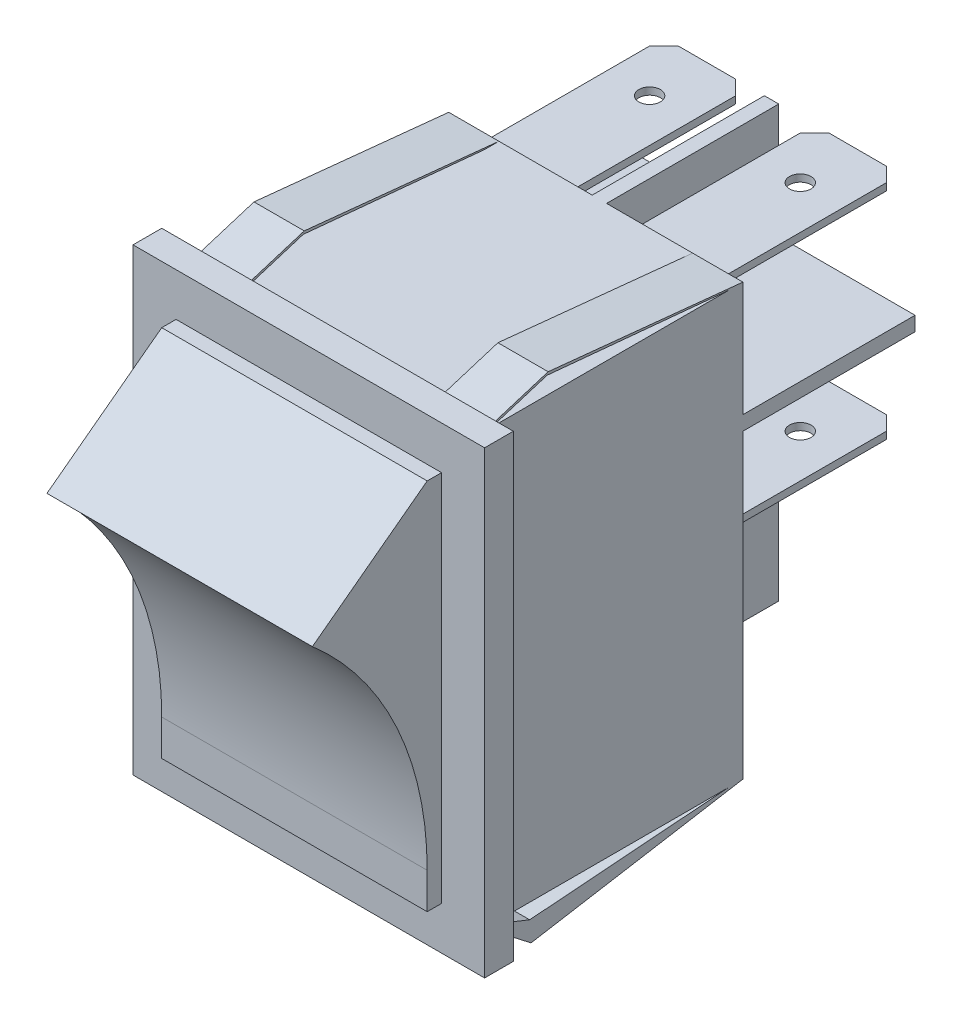
from build123d import *

# Parameters (mm, degrees)
SKETCH1_W                = 24.5
SKETCH1_H                = 32
EXTRUDE2_DEPTH           = 2
SKETCH2_W                = 20.5
SKETCH2_H                = 30
EXTRUDE3_DEPTH           = 18
SKETCH4_W                = 18.5
SKETCH4_H                = 26
EXTRUDE7_DEPTH           = 1
EXTRUDE8_DEPTH           = 18.5
EXTRUDE9_DEPTH           = 3.5
EXTRUDE10_DEPTH          = 3.5
EXTRUDE11_DEPTH          = 3.5
EXTRUDE12_DEPTH          = 3.5
SKETCH10_W               = 1
SKETCH10_H               = 30
EXTRUDE13_DEPTH          = 12
SKETCH11_W               = 9.5
SKETCH11_H               = 1
SKETCH11_W_2             = 10
EXTRUDE14_DEPTH          = 12
SKETCH12_W               = 6
SKETCH12_H               = 0.5
EXTRUDE15_DEPTH          = 13
CHAMFER1_SIZE            = 1
SKETCH14_R               = 0.75
CUT_EXTRUDE2_DEPTH       = 1
TAGLIO_ESTRUSIONE1_REACH = 18.5
SKETCH13_R               = 0.75


with BuildPart() as part:
    # Sketch1 → Extrude2 (new body)
    with BuildSketch(Plane.XY):
        with Locations((-1.666405536, 7.433431257)):
            Rectangle(SKETCH1_W, SKETCH1_H)
    extrude(amount=EXTRUDE2_DEPTH)

    # Sketch2 → Extrude3 (add)
    with BuildSketch(Plane(origin=(0, 0, 0), x_dir=(-1, 0, 0), z_dir=(0, 0, -1))):
        with Locations((1.666405536, 7.433431257)):
            Rectangle(SKETCH2_W, SKETCH2_H)
    extrude(amount=EXTRUDE3_DEPTH)

    # Sketch4 → Extrude7 (add)
    with BuildSketch(Plane.XY.offset(2)):
        with Locations((-1.666405536, 7.433431257)):
            Rectangle(SKETCH4_W, SKETCH4_H)
    extrude(amount=EXTRUDE7_DEPTH)

    # Sketch5 → Extrude8 (add)
    with BuildSketch(Plane.ZY.offset(10.916405536)):
        with BuildLine():
            Line((3, 20.433431257), (3, -3.065691745))
            ThreePointArc((3, -3.065691745), (5.094825857, 6.554850155), (11, 14.433431257))
            Line((11, 14.433431257), (3, 20.433431257))
        make_face()
    extrude(amount=-EXTRUDE8_DEPTH)

    # Sketch6 → Extrude9 (add)
    with BuildSketch(Plane.ZY.offset(11.916405536)):
        Polygon((-18, 22.433431257), (-17, 22.433431257), (-4.359704833, 23.632529834), (-0.5, 22.433431257), (0, 22.433431257), (-4.430049233, 23.809719331), align=None)
    extrude(amount=-EXTRUDE9_DEPTH)

    # Sketch7 → Extrude10 (add)
    with BuildSketch(Plane(origin=(8.583594464, 0, 0), x_dir=(0, 0, -1), z_dir=(1, 0, 0))):
        Polygon((18, 22.433431257), (17.001667285, 22.433431257), (4.359704833, 23.632529834), (0.5, 22.433431257), (0, 22.433431257), (4.430049233, 23.809719331), align=None)
    extrude(amount=-EXTRUDE10_DEPTH)

    # Sketch8 → Extrude11 (add)
    with BuildSketch(Plane(origin=(8.583594464, 0, 0), x_dir=(0, 0, -1), z_dir=(1, 0, 0))):
        Polygon((0, -7.566568743), (0.5, -7.566568743), (3.14109092, -8.623937135), (17, -7.566568743), (18, -7.566568743), (3.237476094, -10.066568743), align=None)
    extrude(amount=-EXTRUDE11_DEPTH)

    # Sketch9 → Extrude12 (add)
    with BuildSketch(Plane.ZY.offset(11.916405536)):
        Polygon((0, -7.566568743), (-0.56008941, -7.566568743), (-3.14109092, -8.623937135), (-17, -7.566568743), (-18, -7.566568743), (-3.237476094, -10.066568743), align=None)
    extrude(amount=-EXTRUDE12_DEPTH)

    # Sketch10 → Extrude13 (add)
    with BuildSketch(Plane(origin=(0, 0, -18), x_dir=(-1, 0, 0), z_dir=(0, 0, -1))):
        with Locations((1.416405536, 7.433431257)):
            Rectangle(SKETCH10_W, SKETCH10_H)
    extrude(amount=EXTRUDE13_DEPTH)

    # Sketch11 → Extrude14 (add)
    with BuildSketch(Plane(origin=(0, 0, -18), x_dir=(-1, 0, 0), z_dir=(0, 0, -1))):
        with Locations((-3.833594464, 13.933431257)):
            Rectangle(SKETCH11_W, SKETCH11_H)
        with Locations((6.916405536, 13.933431257)):
            Rectangle(SKETCH11_W_2, SKETCH11_H)
    extrude(amount=EXTRUDE14_DEPTH)

    # Sketch12 → Extrude15 (add)
    with BuildSketch(Plane(origin=(0, 0, -18), x_dir=(-1, 0, 0), z_dir=(0, 0, -1))):
        with Locations((-3.583594464, 21.183431257)):
            Rectangle(SKETCH12_W, SKETCH12_H)
        with Locations((6.916405536, 21.183431257)):
            Rectangle(SKETCH12_W, SKETCH12_H)
        with Locations((-3.583594464, 6.183431257)):
            Rectangle(SKETCH12_W, SKETCH12_H)
        with Locations((6.916405536, 6.183431257)):
            Rectangle(SKETCH12_W, SKETCH12_H)
    extrude(amount=EXTRUDE15_DEPTH)

    # Chamfer1
    chamfer1_edges = [part.edges().sort_by_distance(p)[0] for p in [
        (6.583594464, 21.183431257, -31),
        (0.583594464, 21.183431257, -31),
        (-3.916405536, 21.183431257, -31),
        (-9.916405536, 21.183431257, -31),
        (6.583594464, 6.183431257, -31),
        (0.583594464, 6.183431257, -31),
        (-3.916405536, 6.183431257, -31),
        (-9.916405536, 6.183431257, -31),
    ]]
    chamfer(chamfer1_edges, length=CHAMFER1_SIZE)

    # Sketch14 → Cut-Extrude2 (cut)
    with BuildSketch(Plane(origin=(0, 21.433431257, 0), x_dir=(1, 0, 0), z_dir=(0, 1, 0))):
        with Locations((-6.916405536, 27)):
            Circle(SKETCH14_R)
        with Locations((3.583594464, 27)):
            Circle(SKETCH14_R)
    extrude(amount=-CUT_EXTRUDE2_DEPTH, mode=Mode.SUBTRACT)

    # Sketch13 → Taglio-Estrusione1 (cut, up to next)
    with BuildSketch(Plane.XZ.offset(-6.433431257), mode=Mode.PRIVATE) as taglio_estrusione1_sk1:
        with Locations((-6.916405536, -27)):
            Circle(SKETCH13_R)
    taglio_estrusione1_tool1 = extrude(taglio_estrusione1_sk1.sketch, amount=TAGLIO_ESTRUSIONE1_REACH, mode=Mode.PRIVATE) & part.part
    add(taglio_estrusione1_tool1.solids().sort_by_distance((-6.916406, 6.433431, -27))[0], mode=Mode.SUBTRACT)
    # Sketch13 → Taglio-Estrusione1 (cut, up to next)
    with BuildSketch(Plane.XZ.offset(-6.433431257), mode=Mode.PRIVATE) as taglio_estrusione1_sk2:
        with Locations((3.583594464, -27)):
            Circle(SKETCH13_R)
    taglio_estrusione1_tool2 = extrude(taglio_estrusione1_sk2.sketch, amount=TAGLIO_ESTRUSIONE1_REACH, mode=Mode.PRIVATE) & part.part
    add(taglio_estrusione1_tool2.solids().sort_by_distance((3.583594, 6.433431, -27))[0], mode=Mode.SUBTRACT)


solid = part.part
